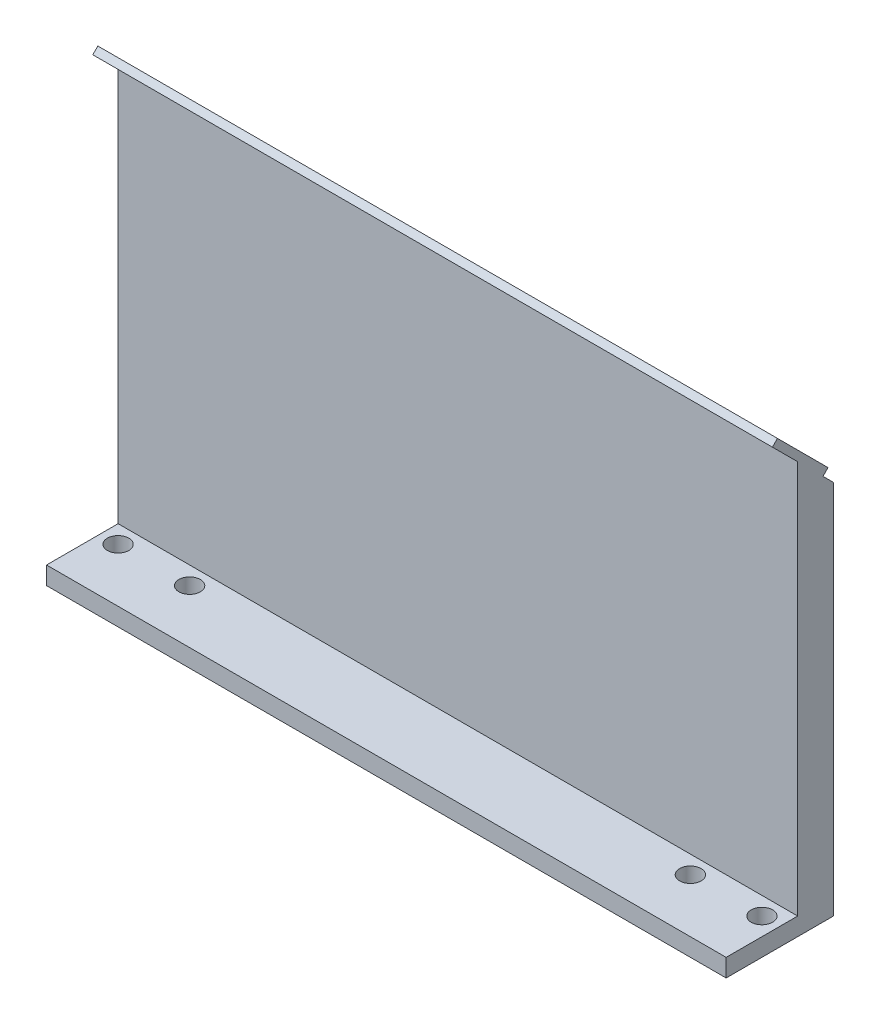
from build123d import *

# Parameters (mm, degrees)
SKETCH1_W           = 241.3
SKETCH1_H           = 38.1
BOSS_EXTRUDE1_DEPTH = 6.35
SKETCH2_R           = 3.81
CUT_EXTRUDE1_DEPTH  = 7.35
SKETCH3_W           = 241.3
SKETCH3_H           = 12.7
BOSS_EXTRUDE2_DEPTH = 139.7
CUT_EXTRUDE4_DEPTH  = 242.3
BOSS_EXTRUDE5_DEPTH = 241.3


with BuildPart() as part:
    # Sketch1 → Boss-Extrude1 (new body)
    with BuildSketch(Plane(origin=(0, 0, 0), x_dir=(1, 0, 0), z_dir=(0, 1, 0))):
        with Locations((24.806115108, 12.928417266)):
            Rectangle(SKETCH1_W, SKETCH1_H)
    extrude(amount=BOSS_EXTRUDE1_DEPTH)

    # Sketch2 → Cut-Extrude1 (cut, through all)
    with BuildSketch(Plane(origin=(0, 6.35, 0), x_dir=(1, 0, 0), z_dir=(0, 1, 0))):
        with Locations((-89.493884892, 12.928417266)):
            Circle(SKETCH2_R)
        with Locations((-64.093884892, 12.928417266)):
            Circle(SKETCH2_R)
        with Locations((113.706115108, 12.928417266)):
            Circle(SKETCH2_R)
        with Locations((139.106115108, 12.928417266)):
            Circle(SKETCH2_R)
    extrude(amount=-CUT_EXTRUDE1_DEPTH, mode=Mode.SUBTRACT)

    # Sketch3 → Boss-Extrude2 (add)
    with BuildSketch(Plane(origin=(0, 6.35, 0), x_dir=(1, 0, 0), z_dir=(0, 1, 0))):
        with Locations((24.806115108, 25.628417266)):
            Rectangle(SKETCH3_W, SKETCH3_H)
    extrude(amount=BOSS_EXTRUDE2_DEPTH)

    # Sketch8 → Cut-Extrude4 (cut, through all)
    with BuildSketch(Plane.ZY.offset(95.843884892)):
        Polygon((-19.278417266, 146.05), (-31.978417266, 146.05), (-31.978417266, 133.35), align=None)
        Polygon((-31.978417266, 133.35), (-31.978417266, 146.05), (-19.278417266, 146.05), (-19.278417266, 148.59), (-34.518417266, 148.59), (-34.518417266, 133.35), align=None)
    extrude(amount=-CUT_EXTRUDE4_DEPTH, mode=Mode.SUBTRACT)

    # Sketch9 → Boss-Extrude5 (add)
    with BuildSketch(Plane.ZY.offset(95.843884892)):
        Polygon((-30.054724611, 138.865795103), (-12.094212369, 156.826307345), (-10.298161145, 155.030256121), (-28.258673387, 137.069743879), align=None)
    extrude(amount=-BOSS_EXTRUDE5_DEPTH)


solid = part.part
